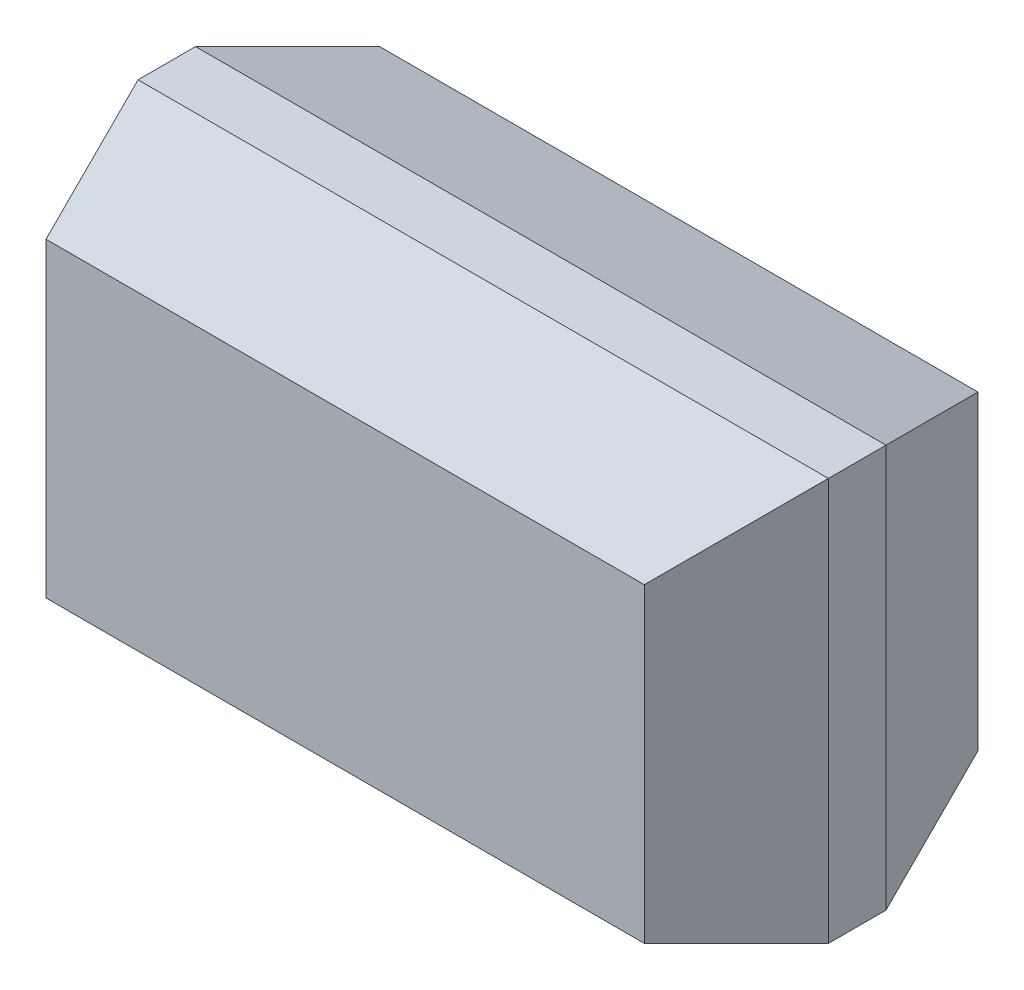
from build123d import *

# Parameters (mm, degrees)
ESQUISSE1_W        = 3
ESQUISSE1_H        = 1.75
BOSS_EXTRU_1_DEPTH = 1.45
CHANFREIN1_SIZE    = 0.6
CHANFREIN1_SIZE2   = 0.2
CHANFREIN2_SIZE    = 0.2
CHANFREIN2_SIZE2   = 0.6
CHANFREIN3_SIZE    = 0.6
CHANFREIN3_SIZE2   = 0.2
CHANFREIN4_SIZE    = 0.2
CHANFREIN4_SIZE2   = 0.6
CHANFREIN5_SIZE    = 0.6
CHANFREIN5_SIZE2   = 0.2
CHANFREIN6_SIZE    = 0.2
CHANFREIN6_SIZE2   = 0.6
CHANFREIN7_SIZE    = 0.6
CHANFREIN7_SIZE2   = 0.2
CHANFREIN8_SIZE    = 0.2
CHANFREIN8_SIZE2   = 0.6


with BuildPart() as part:
    # Esquisse1 → Boss.-Extru.1 (new body)
    with BuildSketch(Plane.XY):
        with Locations((1.5, 0.875)):
            Rectangle(ESQUISSE1_W, ESQUISSE1_H)
    extrude(amount=BOSS_EXTRU_1_DEPTH)

    # Chanfrein1
    chanfrein1_edges = [part.edges().sort_by_distance(p)[0] for p in [
        (1.5, 0, 1.45),
    ]]
    chanfrein1_side = [part.faces().sort_by_distance(p)[0] for p in [
        (1.5, 0, 0.725),
    ]]
    chamfer(chanfrein1_edges, length=CHANFREIN1_SIZE, length2=CHANFREIN1_SIZE2, reference=chanfrein1_side[0])

    # Chanfrein2
    chanfrein2_edges = [part.edges().sort_by_distance(p)[0] for p in [
        (1.5, 0, 0),
    ]]
    chanfrein2_side = [part.faces().sort_by_distance(p)[0] for p in [
        (1.5, 0.875, 0),
    ]]
    chamfer(chanfrein2_edges, length=CHANFREIN2_SIZE, length2=CHANFREIN2_SIZE2, reference=chanfrein2_side[0])

    # Chanfrein3
    chanfrein3_edges = [part.edges().sort_by_distance(p)[0] for p in [
        (1.5, 1.75, 1.45),
    ]]
    chanfrein3_side = [part.faces().sort_by_distance(p)[0] for p in [
        (1.5, 1.75, 0.725),
    ]]
    chamfer(chanfrein3_edges, length=CHANFREIN3_SIZE, length2=CHANFREIN3_SIZE2, reference=chanfrein3_side[0])

    # Chanfrein4
    chanfrein4_edges = [part.edges().sort_by_distance(p)[0] for p in [
        (1.5, 1.75, 0),
    ]]
    chanfrein4_side = [part.faces().sort_by_distance(p)[0] for p in [
        (1.5, 0.975, 0),
    ]]
    chamfer(chanfrein4_edges, length=CHANFREIN4_SIZE, length2=CHANFREIN4_SIZE2, reference=chanfrein4_side[0])

    # Chanfrein5
    chanfrein5_edges = [part.edges().sort_by_distance(p)[0] for p in [
        (0, 0.875, 1.45),
    ]]
    chanfrein5_side = [part.faces().sort_by_distance(p)[0] for p in [
        (0, 0.875, 0.725),
    ]]
    chamfer(chanfrein5_edges, length=CHANFREIN5_SIZE, length2=CHANFREIN5_SIZE2, reference=chanfrein5_side[0])

    # Chanfrein6
    chanfrein6_edges = [part.edges().sort_by_distance(p)[0] for p in [
        (0, 0.875, 0),
    ]]
    chanfrein6_side = [part.faces().sort_by_distance(p)[0] for p in [
        (1.5, 0.875, 0),
    ]]
    chamfer(chanfrein6_edges, length=CHANFREIN6_SIZE, length2=CHANFREIN6_SIZE2, reference=chanfrein6_side[0])

    # Chanfrein7
    chanfrein7_edges = [part.edges().sort_by_distance(p)[0] for p in [
        (3, 0.875, 1.45),
    ]]
    chanfrein7_side = [part.faces().sort_by_distance(p)[0] for p in [
        (3, 0.875, 0.725),
    ]]
    chamfer(chanfrein7_edges, length=CHANFREIN7_SIZE, length2=CHANFREIN7_SIZE2, reference=chanfrein7_side[0])

    # Chanfrein8
    chanfrein8_edges = [part.edges().sort_by_distance(p)[0] for p in [
        (3, 0.875, 0),
    ]]
    chanfrein8_side = [part.faces().sort_by_distance(p)[0] for p in [
        (1.6, 0.875, 0),
    ]]
    chamfer(chanfrein8_edges, length=CHANFREIN8_SIZE, length2=CHANFREIN8_SIZE2, reference=chanfrein8_side[0])


solid = part.part
